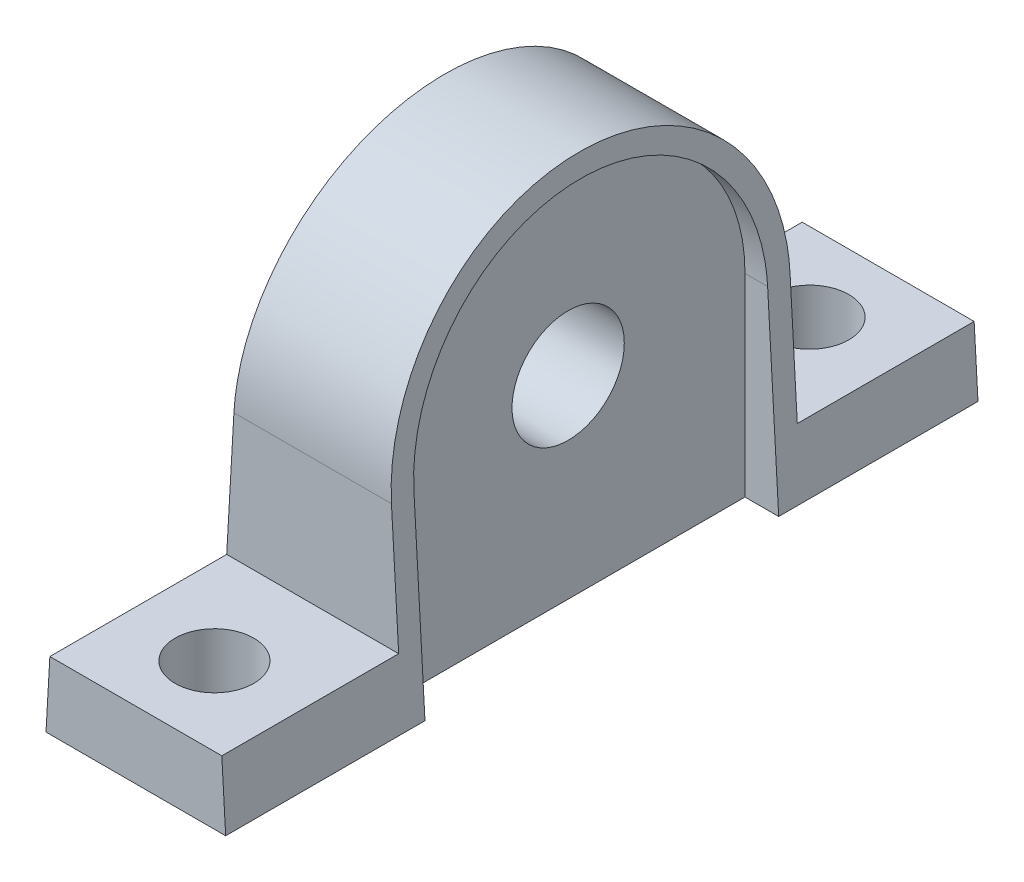
from build123d import *

# Parameters (mm, degrees)
EXTRUDE_1_DEPTH     = 67
SKETCH_2_R          = 5
CUT_EXTRUDE_1_DEPTH = 15
CUT_EXTRUDE_2_DEPTH = 3
SKETCH_4_R          = 7
SKETCH_4_R_2        = 5
EXTRUDE_2_DEPTH     = 5
SKETCH_5_R          = 3.5
CUT_EXTRUDE_4_DEPTH = 10


with BuildPart() as part:
    # 草图1 → 凸台-拉伸1 (new body)
    with BuildSketch(Plane.XY):
        Polygon((8, 0), (-8, 0), (-6, 35), (6, 35), align=None)
    extrude(amount=EXTRUDE_1_DEPTH)

    # 草图2 → 切除-拉伸1 (cut, symmetric)
    with BuildSketch(Plane(origin=(0, 0, 0), x_dir=(0, 0, -1), z_dir=(1, 0, 0))):
        with BuildLine():
            Line((-67, 35), (-67, 6))
            Line((-67, 6), (-51.25, 6))
            Line((-51.25, 6), (-51.25, 17.25))
            ThreePointArc((-51.25, 17.25), (-46.051145366, 29.801145366), (-33.5, 35))
            Line((-33.5, 35), (-67, 35))
        make_face()
        with BuildLine():
            Line((0, 35), (-33.5, 35))
            ThreePointArc((-33.5, 35), (-20.948854634, 29.801145366), (-15.75, 17.25))
            Line((-15.75, 17.25), (-15.75, 6))
            Line((-15.75, 6), (0, 6))
            Line((0, 6), (0, 35))
        make_face()
        with Locations((-33.5, 17.25)):
            Circle(SKETCH_2_R)
    extrude(amount=CUT_EXTRUDE_1_DEPTH, both=True, mode=Mode.SUBTRACT)

    # 草图3 → 切除-拉伸2 (cut)
    with BuildSketch(Plane(origin=(8, 0, 0), x_dir=(0, 0, -1), z_dir=(1, 0, 0))):
        with BuildLine():
            Line((-49.25, 6), (-49.25, 0))
            Line((-49.25, 0), (-17.75, 0))
            Line((-17.75, 0), (-17.75, 6))
            Line((-17.75, 6), (-17.75, 17.25))
            ThreePointArc((-17.75, 17.25), (-33.5, 33), (-49.25, 17.25))
            Line((-49.25, 17.25), (-49.25, 6))
        make_face()
    cut_extrude_2 = extrude(amount=-CUT_EXTRUDE_2_DEPTH, mode=Mode.SUBTRACT)

    # 镜向1: 切除-拉伸2 across plane
    add(cut_extrude_2.mirror(Plane(origin=(0, 0, 0), x_dir=(0, 0, 1), z_dir=(1, 0, 0))), mode=Mode.SUBTRACT)

    # 草图4 → 凸台-拉伸2 (add)
    with BuildSketch(Plane(origin=(-10, 0, 0), x_dir=(0, 0, -1), z_dir=(1, 0, 0))):
        with Locations((-33.5, 17.25)):
            Circle(SKETCH_4_R)
        with Locations((-33.5, 17.25)):
            Circle(SKETCH_4_R_2, mode=Mode.SUBTRACT)
    extrude(amount=EXTRUDE_2_DEPTH)

    # 草图5 → 切除-拉伸4 (cut)
    with BuildSketch(Plane.XZ):
        with Locations((0, 60)):
            Circle(SKETCH_5_R)
        with Locations((0, 7)):
            Circle(SKETCH_5_R)
    extrude(amount=-CUT_EXTRUDE_4_DEPTH, mode=Mode.SUBTRACT)


solid = part.part
